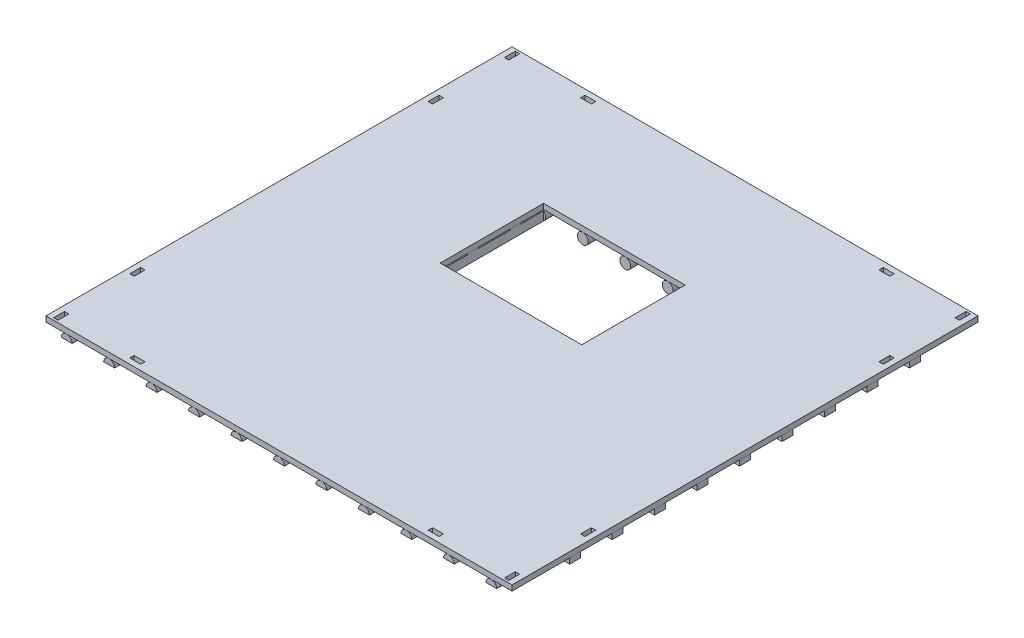
from build123d import *

# Parameters (mm, degrees)
SKETCH_1_W                       = 4280
SKETCH_1_H                       = 4280
EXTRUDE_1_DEPTH                  = 50
SKETCH_2_R                       = 50
EXTRUDE_3_DEPTH                  = 4280
SKETCH_3_W                       = 100
SKETCH_3_H                       = 100
CUT_EXTRUDE_1_DEPTH              = 140
SKETCH_4_W                       = 100
SKETCH_4_H                       = 100
CUT_EXTRUDE_2_DEPTH              = 140
PATTERN_LINEAR_2_COUNT           = 11
PATTERN_LINEAR_2_PITCH           = 390
PATTERN_LINEAR_2_2_COUNT         = 11
PATTERN_LINEAR_2_2_PITCH         = 390
SKETCH_5_W                       = 100
SKETCH_5_H                       = 30
CUT_EXTRUDE_3_DEPTH              = 4280
SKETCH_6_W                       = 100
SKETCH_6_H                       = 29.99
EXTRUDE_6_DEPTH                  = 4280
SKETCH_7_W                       = 100
SKETCH_7_H                       = 100
EXTRUDE_9_DEPTH                  = 20
SKETCH_8_W                       = 100
SKETCH_8_H                       = 100
EXTRUDE_10_DEPTH                 = 20
PATTERN_LINEAR_3_COUNT           = 9
PATTERN_LINEAR_3_PITCH           = 390
SKETCH_9_W                       = 40
SKETCH_9_H                       = 100
CUT_EXTRUDE_4_DEPTH              = 6054.66004992
PATTERN_LINEAR_4_COUNT           = 2
PATTERN_LINEAR_4_PITCH           = 4140
PATTERN_LINEAR_4_COUNT_DIR2      = 2
PATTERN_LINEAR_4_PITCH_DIR2      = 4140
SKETCH_10_W                      = 40
SKETCH_10_H                      = 100
CUT_EXTRUDE_5_DEPTH              = 6054.66004992
PATTERN_LINEAR_5_COUNT           = 2
PATTERN_LINEAR_5_PITCH           = 4140
PATTERN_LINEAR_6_COPY_1_SKETCH_W = 40
PATTERN_LINEAR_6_COPY_1_SKETCH_H = 100
PATTERN_LINEAR_6_COPY_1_DEPTH    = 6054.66004992
PATTERN_LINEAR_6_COPY_2_SKETCH_W = 40
PATTERN_LINEAR_6_COPY_2_SKETCH_H = 100
PATTERN_LINEAR_6_COPY_2_DEPTH    = 6054.66004992
SKETCH_11_W                      = 100
SKETCH_11_H                      = 40
CUT_EXTRUDE_6_DEPTH              = 100
PATTERN_LINEAR_7_COUNT           = 2
PATTERN_LINEAR_7_PITCH           = 2740
PATTERN_LINEAR_7_COUNT_DIR2      = 2
PATTERN_LINEAR_7_PITCH_DIR2      = 4140
SKETCH_12_W                      = 1300
SKETCH_12_H                      = 950
CUT_EXTRUDE_7_DEPTH              = 6055.692395159


with BuildPart() as part:
    # 草图1 → 凸台-拉伸1 (new body)
    with BuildSketch(Plane(origin=(0, 0, 0), x_dir=(1, 0, 0), z_dir=(0, 1, 0))):
        with Locations((2140, 2140)):
            Rectangle(SKETCH_1_W, SKETCH_1_H)
    extrude(amount=EXTRUDE_1_DEPTH)

    # 草图9 → 切除-拉伸4 (cut, through all)
    with BuildSketch(Plane.XZ):
        with Locations((70, -70)):
            Rectangle(SKETCH_9_W, SKETCH_9_H)
    cut_extrude_4 = extrude(amount=-CUT_EXTRUDE_4_DEPTH, mode=Mode.SUBTRACT)

    # 阵列(线性)4: Cut-Extrude 4 2 × 2
    with Locations(*[(i * PATTERN_LINEAR_4_PITCH, 0, -j * PATTERN_LINEAR_4_PITCH_DIR2) for i in range(PATTERN_LINEAR_4_COUNT) for j in range(PATTERN_LINEAR_4_COUNT_DIR2) if (i, j) != (0, 0)]):
        add(cut_extrude_4, mode=Mode.SUBTRACT)

    # 草图10 → 切除-拉伸5 (cut, through all)
    with BuildSketch(Plane.XZ):
        with Locations((70, -770)):
            Rectangle(SKETCH_10_W, SKETCH_10_H)
    cut_extrude_5 = extrude(amount=-CUT_EXTRUDE_5_DEPTH, mode=Mode.SUBTRACT)

    # 阵列(线性)5: 切除-拉伸5 ×2
    with Locations(*[(i * PATTERN_LINEAR_5_PITCH, 0, 0) for i in range(1, PATTERN_LINEAR_5_COUNT)]):
        add(cut_extrude_5, mode=Mode.SUBTRACT)

    # 阵列(线性)6 copy 1 sketch → 阵列(线性)6 copy 1 (cut, through all)
    with BuildSketch(Plane(origin=(4140, 0, -2740), x_dir=(1, 0, 0), z_dir=(0, -1, 0))):
        with Locations((70, -770)):
            Rectangle(PATTERN_LINEAR_6_COPY_1_SKETCH_W, PATTERN_LINEAR_6_COPY_1_SKETCH_H)
    extrude(amount=-PATTERN_LINEAR_6_COPY_1_DEPTH, mode=Mode.SUBTRACT)

    # 阵列(线性)6 copy 2 sketch → 阵列(线性)6 copy 2 (cut, through all)
    with BuildSketch(Plane(origin=(0, 0, -2740), x_dir=(1, 0, 0), z_dir=(0, -1, 0))):
        with Locations((70, -770)):
            Rectangle(PATTERN_LINEAR_6_COPY_2_SKETCH_W, PATTERN_LINEAR_6_COPY_2_SKETCH_H)
    extrude(amount=-PATTERN_LINEAR_6_COPY_2_DEPTH, mode=Mode.SUBTRACT)

    # 草图11 → 切除-拉伸6 (cut)
    with BuildSketch(Plane.XZ):
        with Locations((770, -70)):
            Rectangle(SKETCH_11_W, SKETCH_11_H)
    cut_extrude_6 = extrude(amount=-CUT_EXTRUDE_6_DEPTH, mode=Mode.SUBTRACT)

    # 阵列(线性)7: Cut-Extrude 6 2 × 2
    with Locations(*[(i * PATTERN_LINEAR_7_PITCH, 0, -j * PATTERN_LINEAR_7_PITCH_DIR2) for i in range(PATTERN_LINEAR_7_COUNT) for j in range(PATTERN_LINEAR_7_COUNT_DIR2) if (i, j) != (0, 0)]):
        add(cut_extrude_6, mode=Mode.SUBTRACT)


with BuildPart() as body_2:
    # 草图2 → 凸台-拉伸3 (new body)
    with BuildSketch(Plane.XY):
        with Locations((190, -50)):
            Circle(SKETCH_2_R)
    extrude_3 = extrude(amount=-EXTRUDE_3_DEPTH)

    # 草图3 → 切除-拉伸1 (cut)
    with BuildSketch(Plane.XY):
        with Locations((190, -100)):
            Rectangle(SKETCH_3_W, SKETCH_3_H)
    cut_extrude_1 = extrude(amount=-CUT_EXTRUDE_1_DEPTH, mode=Mode.SUBTRACT)

    # 草图4 → 切除-拉伸2 (cut)
    with BuildSketch(Plane(origin=(0, 0, -4280), x_dir=(-1, 0, 0), z_dir=(0, 0, -1))):
        with Locations((-190, -100)):
            Rectangle(SKETCH_4_W, SKETCH_4_H)
    cut_extrude_2 = extrude(amount=-CUT_EXTRUDE_2_DEPTH, mode=Mode.SUBTRACT)


with BuildPart() as pattern_linear_2_1:
    # 阵列(线性)2: pattern copy
    add(extrude_3.moved(Location(Vector(1, 0, 0) * (1 * PATTERN_LINEAR_2_PITCH))))


with BuildPart() as pattern_linear_2_2:
    # 阵列(线性)2: pattern copy
    add(extrude_3.moved(Location(Vector(1, 0, 0) * (2 * PATTERN_LINEAR_2_PITCH))))


with BuildPart() as pattern_linear_2_3:
    # 阵列(线性)2: pattern copy
    add(extrude_3.moved(Location(Vector(1, 0, 0) * (3 * PATTERN_LINEAR_2_PITCH))))


with BuildPart() as pattern_linear_2_4:
    # 阵列(线性)2: pattern copy
    add(extrude_3.moved(Location(Vector(1, 0, 0) * (4 * PATTERN_LINEAR_2_PITCH))))


with BuildPart() as pattern_linear_2_5:
    # 阵列(线性)2: pattern copy
    add(extrude_3.moved(Location(Vector(1, 0, 0) * (5 * PATTERN_LINEAR_2_PITCH))))


with BuildPart() as pattern_linear_2_6:
    # 阵列(线性)2: pattern copy
    add(extrude_3.moved(Location(Vector(1, 0, 0) * (6 * PATTERN_LINEAR_2_PITCH))))


with BuildPart() as pattern_linear_2_7:
    # 阵列(线性)2: pattern copy
    add(extrude_3.moved(Location(Vector(1, 0, 0) * (7 * PATTERN_LINEAR_2_PITCH))))


with BuildPart() as pattern_linear_2_8:
    # 阵列(线性)2: pattern copy
    add(extrude_3.moved(Location(Vector(1, 0, 0) * (8 * PATTERN_LINEAR_2_PITCH))))


with BuildPart() as pattern_linear_2_9:
    # 阵列(线性)2: pattern copy
    add(extrude_3.moved(Location(Vector(1, 0, 0) * (9 * PATTERN_LINEAR_2_PITCH))))


with BuildPart() as pattern_linear_2_10:
    # 阵列(线性)2: pattern copy
    add(extrude_3.moved(Location(Vector(1, 0, 0) * (10 * PATTERN_LINEAR_2_PITCH))))


with BuildPart() as pattern_linear_2_2_tool:
    # Pattern Linear 2 2: 切除-拉伸1, 切除-拉伸2 ×11
    with Locations(*[(i * PATTERN_LINEAR_2_2_PITCH, 0, 0) for i in range(1, PATTERN_LINEAR_2_2_COUNT)]):
        add(cut_extrude_1)
        add(cut_extrude_2)


with BuildPart() as pattern_linear_2_1_1:
    add(pattern_linear_2_1.part)

    # Pattern Linear 2 2: cut by pattern_linear_2_2_tool
    add(pattern_linear_2_2_tool.part, mode=Mode.SUBTRACT)


with BuildPart() as pattern_linear_2_2_1:
    add(pattern_linear_2_2.part)

    # Pattern Linear 2 2: cut by pattern_linear_2_2_tool
    add(pattern_linear_2_2_tool.part, mode=Mode.SUBTRACT)


with BuildPart() as pattern_linear_2_3_1:
    add(pattern_linear_2_3.part)

    # Pattern Linear 2 2: cut by pattern_linear_2_2_tool
    add(pattern_linear_2_2_tool.part, mode=Mode.SUBTRACT)


with BuildPart() as pattern_linear_2_4_1:
    add(pattern_linear_2_4.part)

    # Pattern Linear 2 2: cut by pattern_linear_2_2_tool
    add(pattern_linear_2_2_tool.part, mode=Mode.SUBTRACT)


with BuildPart() as pattern_linear_2_5_1:
    add(pattern_linear_2_5.part)

    # Pattern Linear 2 2: cut by pattern_linear_2_2_tool
    add(pattern_linear_2_2_tool.part, mode=Mode.SUBTRACT)


with BuildPart() as pattern_linear_2_6_1:
    add(pattern_linear_2_6.part)

    # Pattern Linear 2 2: cut by pattern_linear_2_2_tool
    add(pattern_linear_2_2_tool.part, mode=Mode.SUBTRACT)


with BuildPart() as pattern_linear_2_7_1:
    add(pattern_linear_2_7.part)

    # Pattern Linear 2 2: cut by pattern_linear_2_2_tool
    add(pattern_linear_2_2_tool.part, mode=Mode.SUBTRACT)


with BuildPart() as pattern_linear_2_8_1:
    add(pattern_linear_2_8.part)

    # Pattern Linear 2 2: cut by pattern_linear_2_2_tool
    add(pattern_linear_2_2_tool.part, mode=Mode.SUBTRACT)


with BuildPart() as pattern_linear_2_9_1:
    add(pattern_linear_2_9.part)

    # Pattern Linear 2 2: cut by pattern_linear_2_2_tool
    add(pattern_linear_2_2_tool.part, mode=Mode.SUBTRACT)


with BuildPart() as pattern_linear_2_10_1:
    add(pattern_linear_2_10.part)

    # Pattern Linear 2 2: cut by pattern_linear_2_2_tool
    add(pattern_linear_2_2_tool.part, mode=Mode.SUBTRACT)


with BuildPart() as cut_extrude_3_tool:
    # 草图5 → 切除-拉伸3 (new body)
    with BuildSketch(Plane(origin=(4280, 0, 0), x_dir=(0, 0, -1), z_dir=(1, 0, 0))):
        with Locations((580, -15)):
            Rectangle(SKETCH_5_W, SKETCH_5_H)
    extrude(amount=-CUT_EXTRUDE_3_DEPTH)


with BuildPart() as body_2_1:
    add(body_2.part)

    # 切除-拉伸3: cut by cut_extrude_3_tool
    add(cut_extrude_3_tool.part, mode=Mode.SUBTRACT)



with BuildPart() as pattern_linear_2_1_2:
    add(pattern_linear_2_1_1.part)

    # 切除-拉伸3: cut by cut_extrude_3_tool
    add(cut_extrude_3_tool.part, mode=Mode.SUBTRACT)


with BuildPart() as pattern_linear_2_2_2:
    add(pattern_linear_2_2_1.part)

    # 切除-拉伸3: cut by cut_extrude_3_tool
    add(cut_extrude_3_tool.part, mode=Mode.SUBTRACT)


with BuildPart() as pattern_linear_2_3_2:
    add(pattern_linear_2_3_1.part)

    # 切除-拉伸3: cut by cut_extrude_3_tool
    add(cut_extrude_3_tool.part, mode=Mode.SUBTRACT)


with BuildPart() as pattern_linear_2_4_2:
    add(pattern_linear_2_4_1.part)

    # 切除-拉伸3: cut by cut_extrude_3_tool
    add(cut_extrude_3_tool.part, mode=Mode.SUBTRACT)


with BuildPart() as pattern_linear_2_5_2:
    add(pattern_linear_2_5_1.part)

    # 切除-拉伸3: cut by cut_extrude_3_tool
    add(cut_extrude_3_tool.part, mode=Mode.SUBTRACT)


with BuildPart() as pattern_linear_2_6_2:
    add(pattern_linear_2_6_1.part)

    # 切除-拉伸3: cut by cut_extrude_3_tool
    add(cut_extrude_3_tool.part, mode=Mode.SUBTRACT)


with BuildPart() as pattern_linear_2_7_2:
    add(pattern_linear_2_7_1.part)

    # 切除-拉伸3: cut by cut_extrude_3_tool
    add(cut_extrude_3_tool.part, mode=Mode.SUBTRACT)


with BuildPart() as pattern_linear_2_8_2:
    add(pattern_linear_2_8_1.part)

    # 切除-拉伸3: cut by cut_extrude_3_tool
    add(cut_extrude_3_tool.part, mode=Mode.SUBTRACT)


with BuildPart() as pattern_linear_2_9_2:
    add(pattern_linear_2_9_1.part)

    # 切除-拉伸3: cut by cut_extrude_3_tool
    add(cut_extrude_3_tool.part, mode=Mode.SUBTRACT)


with BuildPart() as pattern_linear_2_10_2:
    add(pattern_linear_2_10_1.part)

    # 切除-拉伸3: cut by cut_extrude_3_tool
    add(cut_extrude_3_tool.part, mode=Mode.SUBTRACT)


with BuildPart() as body_2_2:
    add(body_2_1.part)

    add(pattern_linear_2_1_2.part)  # 凸台-拉伸6 merges 阵列(线性)2_1

    add(pattern_linear_2_2_2.part)  # 凸台-拉伸6 merges 阵列(线性)2_2

    add(pattern_linear_2_3_2.part)  # 凸台-拉伸6 merges 阵列(线性)2_3

    add(pattern_linear_2_4_2.part)  # 凸台-拉伸6 merges 阵列(线性)2_4

    add(pattern_linear_2_5_2.part)  # 凸台-拉伸6 merges 阵列(线性)2_5

    add(pattern_linear_2_6_2.part)  # 凸台-拉伸6 merges 阵列(线性)2_6

    add(pattern_linear_2_7_2.part)  # 凸台-拉伸6 merges 阵列(线性)2_7

    add(pattern_linear_2_8_2.part)  # 凸台-拉伸6 merges 阵列(线性)2_8

    add(pattern_linear_2_9_2.part)  # 凸台-拉伸6 merges 阵列(线性)2_9

    add(pattern_linear_2_10_2.part)  # 凸台-拉伸6 merges 阵列(线性)2_10
    # 草图6 → 凸台-拉伸6 (add)
    with BuildSketch(Plane(origin=(4280, 0, 0), x_dir=(0, 0, -1), z_dir=(1, 0, 0))):
        with Locations((580, -15.005)):
            Rectangle(SKETCH_6_W, SKETCH_6_H)
    extrude_6 = extrude(amount=-EXTRUDE_6_DEPTH)

    # 草图7 → 凸台-拉伸9 (add)
    with BuildSketch(Plane.XZ.offset(30)):
        with Locations((4230, -580)):
            Rectangle(SKETCH_7_W, SKETCH_7_H)
    extrude_9 = extrude(amount=EXTRUDE_9_DEPTH)

    # 草图8 → 凸台-拉伸10 (add)
    with BuildSketch(Plane.XZ.offset(30)):
        with Locations((50, -580)):
            Rectangle(SKETCH_8_W, SKETCH_8_H)
    extrude_10 = extrude(amount=EXTRUDE_10_DEPTH)

    # 阵列(线性)3: 凸台-拉伸6, 凸台-拉伸9, 凸台-拉伸10 ×9
    with Locations(*[(0, 0, -i * PATTERN_LINEAR_3_PITCH) for i in range(1, PATTERN_LINEAR_3_COUNT)]):
        add(extrude_6)
        add(extrude_9)
        add(extrude_10)


with BuildPart() as cut_extrude_7_tool:
    # 草图12 → 切除-拉伸7 (new, through all)
    with BuildSketch(Plane(origin=(0, 50, 0), x_dir=(1, 0, 0), z_dir=(0, 1, 0))):
        with Locations((2040, 2705)):
            Rectangle(SKETCH_12_W, SKETCH_12_H)
    extrude(amount=-CUT_EXTRUDE_7_DEPTH)


with BuildPart() as part_1:
    add(part.part)

    # 切除-拉伸7: cut by cut_extrude_7_tool
    add(cut_extrude_7_tool.part, mode=Mode.SUBTRACT)


with BuildPart() as body_2_3:
    add(body_2_2.part)

    # 切除-拉伸7: cut by cut_extrude_7_tool
    add(cut_extrude_7_tool.part, mode=Mode.SUBTRACT)


solid = Compound([part_1.part, body_2_3.part])
